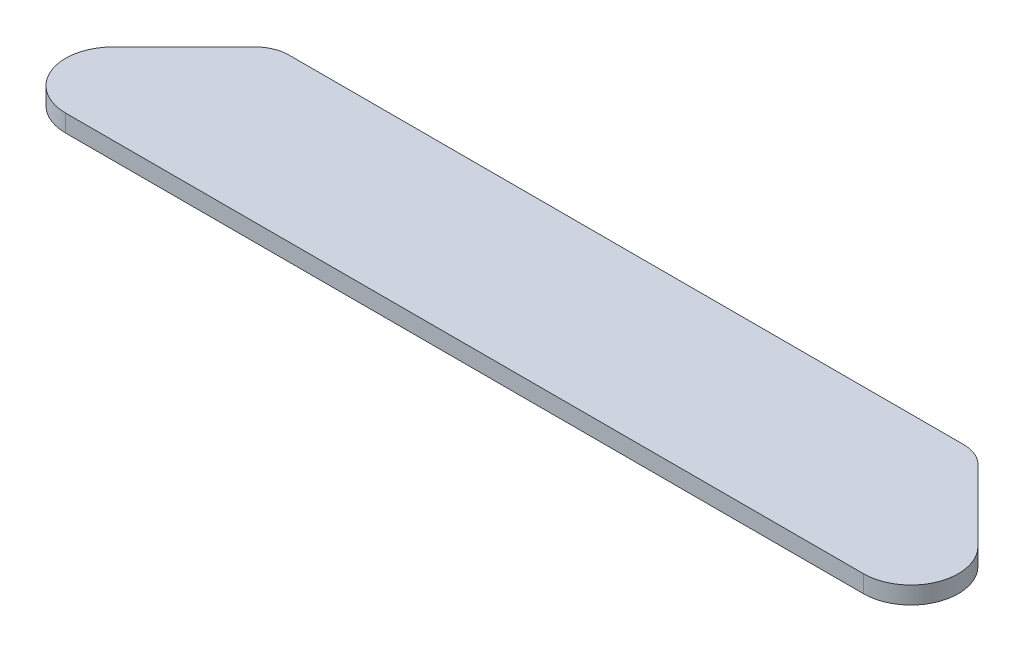
from build123d import *

# Parameters (mm, degrees)
BOSS_EXTRUDE1_DEPTH = 38.1
SKETCH2_R           = 12.7
CUT_EXTRUDE1_DEPTH  = 12.7


with BuildPart() as part:
    # Sketch1 → Boss-Extrude1 (new body)
    with BuildSketch(Plane(origin=(0, 0, 0), x_dir=(1, 0, 0), z_dir=(0, 1, 0))):
        with BuildLine():
            Line((-1003.209151546, 19.574124673), (-852.041766236, 170.741509982))
            Line((-852.041766236, 170.741509982), (-851.297817461, 171.485458758))
            ThreePointArc((-851.297817461, 171.485458758), (-827.400793586, 187.45293962), (-799.212331958, 193.059973256))
            Line((-799.212331958, 193.059973256), (-752.46588673, 193.059973256))
            Line((-752.46588673, 193.059973256), (636.970077719, 193.059973256))
            Line((636.970077719, 193.059973256), (682.664420499, 193.059973256))
            ThreePointArc((682.664420499, 193.059973256), (711.824898045, 187.259593633), (736.545957225, 170.741509982))
            Line((736.545957225, 170.741509982), (892.049393759, 15.238073448))
            ThreePointArc((892.049393759, 15.238073448), (914.624108082, -98.252679391), (818.411293566, -162.540026744))
            Line((818.411293566, -162.540026744), (812.279191118, -162.540026744))
            Line((812.279191118, -162.540026744), (-927.775000129, -162.540026744))
            Line((-927.775000129, -162.540026744), (-933.907102577, -162.540026744))
            ThreePointArc((-933.907102577, -162.540026744), (-1030.119917093, -98.252679391), (-1007.54520277, 15.238073448))
            Line((-1007.54520277, 15.238073448), (-1003.209151546, 19.574124673))
        make_face()
    extrude(amount=BOSS_EXTRUDE1_DEPTH)

    # Sketch2 → Cut-Extrude1 (cut)
    with BuildSketch(Plane.XZ):
        with Locations((-629.107102577, 58.400026744)):
            Circle(SKETCH2_R)
        with Locations((513.611293566, 58.400026744)):
            Circle(SKETCH2_R)
    extrude(amount=-CUT_EXTRUDE1_DEPTH, mode=Mode.SUBTRACT)


solid = part.part
